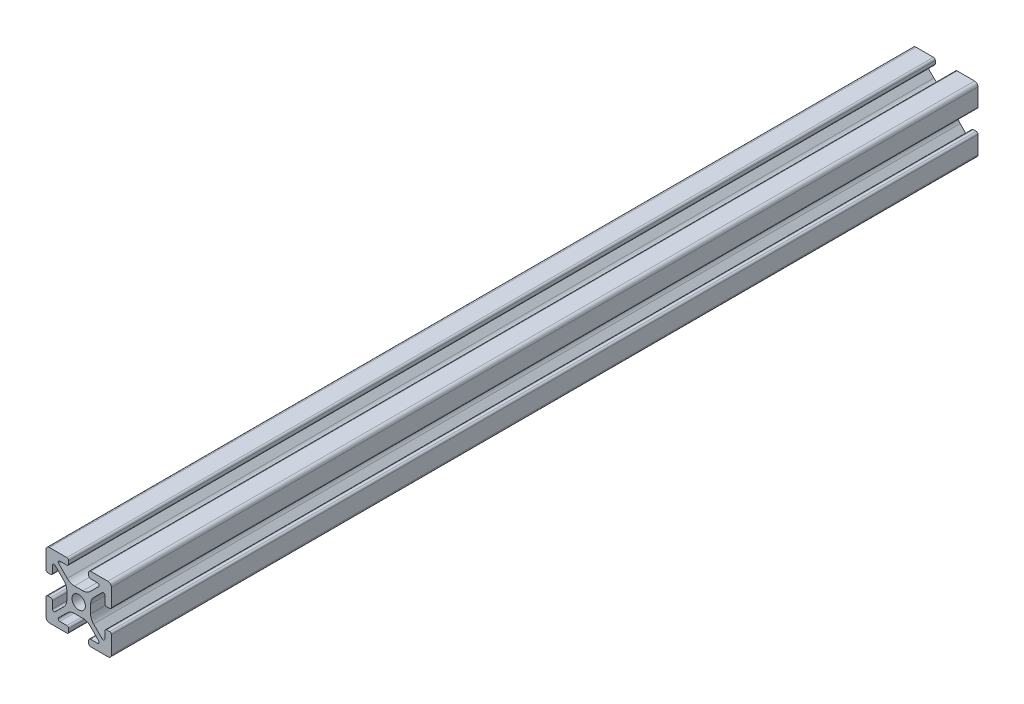
from build123d import *

# Parameters (mm, degrees)
SKETCH1_R           = 2.05
BOSS_EXTRUDE1_DEPTH = 265


with BuildPart() as part:
    # Sketch1 → Boss-Extrude1 (new body)
    with BuildSketch(Plane.XY):
        with BuildLine():
            Line((-3.642230561, 1.287773026), (-3.642230561, -1.287773026))
            ThreePointArc((-3.642230561, -1.287773026), (-3.87999308, -2.483085929), (-4.55708345, -3.496423279))
            Line((-4.55708345, -3.496423279), (-7.182004606, -6.121344434))
            ThreePointArc((-7.182004606, -6.121344434), (-7.704200045, -6.225215565), (-8, -5.782519648))
            Line((-8, -5.782519648), (-8, -3.622007668))
            ThreePointArc((-8, -3.622007668), (-8.161974206, -3.230967343), (-8.553014531, -3.068993137))
            Line((-8.553014531, -3.068993137), (-9.443284204, -3.068993137))
            ThreePointArc((-9.443284204, -3.068993137), (-9.836715763, -3.229656566), (-10, -3.622007668))
            Line((-10, -3.622007668), (-10, -8.939033256))
            ThreePointArc((-10, -8.939033256), (-9.689250035, -9.689250035), (-8.939033256, -10))
            Line((-8.939033256, -10), (-3.622007668, -10))
            ThreePointArc((-3.622007668, -10), (-3.229656566, -9.836715763), (-3.068993137, -9.443284204))
            Line((-3.068993137, -9.443284204), (-3.068993137, -8.553014531))
            ThreePointArc((-3.068993137, -8.553014531), (-3.230967343, -8.161974206), (-3.622007668, -8))
            Line((-3.622007668, -8), (-5.782519648, -8))
            ThreePointArc((-5.782519648, -8), (-6.225215565, -7.704200045), (-6.121344434, -7.182004606))
            Line((-6.121344434, -7.182004606), (-3.496423279, -4.55708345))
            ThreePointArc((-3.496423279, -4.55708345), (-2.483085929, -3.87999308), (-1.287773026, -3.642230561))
            Line((-1.287773026, -3.642230561), (1.287773026, -3.642230561))
            ThreePointArc((1.287773026, -3.642230561), (2.483085929, -3.87999308), (3.496423279, -4.55708345))
            Line((3.496423279, -4.55708345), (6.121344434, -7.182004606))
            ThreePointArc((6.121344434, -7.182004606), (6.225215565, -7.704200045), (5.782519648, -8))
            Line((5.782519648, -8), (3.622007668, -8))
            ThreePointArc((3.622007668, -8), (3.230967343, -8.161974206), (3.068993137, -8.553014531))
            Line((3.068993137, -8.553014531), (3.068993137, -9.443284204))
            ThreePointArc((3.068993137, -9.443284204), (3.229656566, -9.836715763), (3.622007668, -10))
            Line((3.622007668, -10), (8.939033256, -10))
            ThreePointArc((8.939033256, -10), (9.689250035, -9.689250035), (10, -8.939033256))
            Line((10, -8.939033256), (10, -3.622007668))
            ThreePointArc((10, -3.622007668), (9.836715763, -3.229656566), (9.443284204, -3.068993137))
            Line((9.443284204, -3.068993137), (8.553014531, -3.068993137))
            ThreePointArc((8.553014531, -3.068993137), (8.161974206, -3.230967343), (8, -3.622007668))
            Line((8, -3.622007668), (8, -5.782519648))
            ThreePointArc((8, -5.782519648), (7.704200045, -6.225215565), (7.182004606, -6.121344434))
            Line((7.182004606, -6.121344434), (4.55708345, -3.496423279))
            ThreePointArc((4.55708345, -3.496423279), (3.87999308, -2.483085929), (3.642230561, -1.287773026))
            Line((3.642230561, -1.287773026), (3.642230561, 1.287773026))
            ThreePointArc((3.642230561, 1.287773026), (3.87999308, 2.483085929), (4.55708345, 3.496423279))
            Line((4.55708345, 3.496423279), (7.182004606, 6.121344434))
            ThreePointArc((7.182004606, 6.121344434), (7.704200045, 6.225215565), (8, 5.782519648))
            Line((8, 5.782519648), (8, 3.622007668))
            ThreePointArc((8, 3.622007668), (8.161974206, 3.230967343), (8.553014531, 3.068993137))
            Line((8.553014531, 3.068993137), (9.443284204, 3.068993137))
            ThreePointArc((9.443284204, 3.068993137), (9.836715763, 3.229656566), (10, 3.622007668))
            Line((10, 3.622007668), (10, 8.939033256))
            ThreePointArc((10, 8.939033256), (9.689250035, 9.689250035), (8.939033256, 10))
            Line((8.939033256, 10), (3.622007668, 10))
            ThreePointArc((3.622007668, 10), (3.229656566, 9.836715763), (3.068993137, 9.443284204))
            Line((3.068993137, 9.443284204), (3.068993137, 8.553014531))
            ThreePointArc((3.068993137, 8.553014531), (3.230967343, 8.161974206), (3.622007668, 8))
            Line((3.622007668, 8), (5.782519648, 8))
            ThreePointArc((5.782519648, 8), (6.225215565, 7.704200045), (6.121344434, 7.182004606))
            Line((6.121344434, 7.182004606), (3.496423279, 4.55708345))
            ThreePointArc((3.496423279, 4.55708345), (2.483085929, 3.87999308), (1.287773026, 3.642230561))
            Line((1.287773026, 3.642230561), (-1.287773026, 3.642230561))
            ThreePointArc((-1.287773026, 3.642230561), (-2.483085929, 3.87999308), (-3.496423279, 4.55708345))
            Line((-3.496423279, 4.55708345), (-6.121344434, 7.182004606))
            ThreePointArc((-6.121344434, 7.182004606), (-6.225215565, 7.704200045), (-5.782519648, 8))
            Line((-5.782519648, 8), (-3.622007668, 8))
            ThreePointArc((-3.622007668, 8), (-3.230967343, 8.161974206), (-3.068993137, 8.553014531))
            Line((-3.068993137, 8.553014531), (-3.068993137, 9.443284204))
            ThreePointArc((-3.068993137, 9.443284204), (-3.229656566, 9.836715763), (-3.622007668, 10))
            Line((-3.622007668, 10), (-8.939033256, 10))
            ThreePointArc((-8.939033256, 10), (-9.689250035, 9.689250035), (-10, 8.939033256))
            Line((-10, 8.939033256), (-10, 3.622007668))
            ThreePointArc((-10, 3.622007668), (-9.836715763, 3.229656566), (-9.443284204, 3.068993137))
            Line((-9.443284204, 3.068993137), (-8.553014531, 3.068993137))
            ThreePointArc((-8.553014531, 3.068993137), (-8.161974206, 3.230967343), (-8, 3.622007668))
            Line((-8, 3.622007668), (-8, 5.782519648))
            ThreePointArc((-8, 5.782519648), (-7.704200045, 6.225215565), (-7.182004606, 6.121344434))
            Line((-7.182004606, 6.121344434), (-4.55708345, 3.496423279))
            ThreePointArc((-4.55708345, 3.496423279), (-3.87999308, 2.483085929), (-3.642230561, 1.287773026))
        make_face()
        Circle(SKETCH1_R, mode=Mode.SUBTRACT)
    extrude(amount=-BOSS_EXTRUDE1_DEPTH)


solid = part.part
